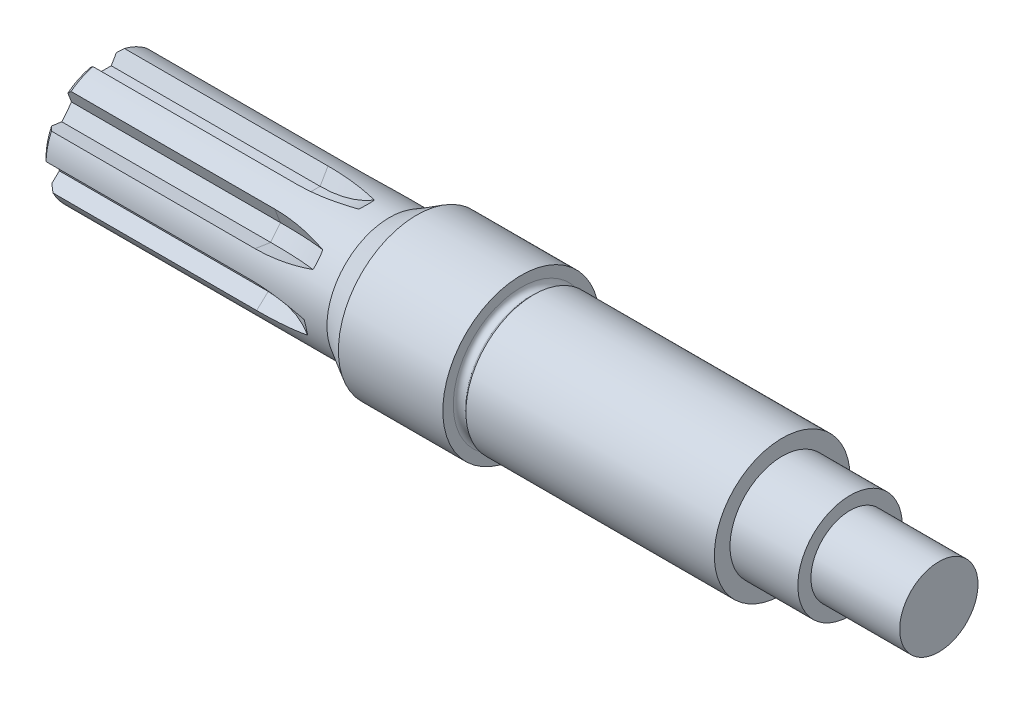
from build123d import *

# Parameters (mm, degrees)
KRUHOV_POLE1_COUNT = 7


with BuildPart() as part:
    # Skica1 → Rotovat1 (revolve)
    with BuildSketch(Plane.XY, mode=Mode.PRIVATE) as rotovat1_sk:
        with BuildLine():
            Line((-80, 2.5), (-61.443375673, 2.5))
            Line((-61.443375673, 2.5), (-60, 0))
            Line((-60, 0), (80, 0))
            Line((80, 0), (80, 7.5))
            Line((80, 7.5), (63, 7.5))
            Line((63, 7.5), (63, 10))
            Line((63, 10), (50, 10))
            Line((50, 10), (50, 13))
            Line((50, 13), (2.414213562, 13))
            Line((2.414213562, 13), (1.707106781, 12.292893219))
            ThreePointArc((1.707106781, 12.292893219), (0.617316568, 12.076120467), (0, 13))
            Line((0, 13), (0, 15))
            Line((0, 15), (-20, 15))
            Line((-20, 15), (-25.196152423, 12))
            Line((-25.196152423, 12), (-79, 12))
            Line((-79, 12), (-80, 11))
            Line((-80, 11), (-80, 2.5))
        make_face()
    revolve(rotovat1_sk.sketch.rotate(Axis((89.49015633, 0, 0), (-1, 0, 0)), 90), axis=Axis((89.49015633, 0, 0), (-1, 0, 0)))  # turned: the seam where the file's is

    # Odebrat tažením po křivce1: sweep along a path in Skica2
    with BuildLine(Plane.XY) as odebrat_ta_en_m_po_k_ivce1_path:
        Line((-80, 9), (-40, 9))
        ThreePointArc((-40, 9), (-30.024182748, 11.665552499), (-22.707471957, 18.951692985))
    # Skica3 → Odebrat tažením po křivce1 (sweep, cut)
    with BuildSketch(Plane.ZY.offset(80)):
        Polygon((-4.16819533, 13.621449875), (-1.5, 9), (1.5, 9), (4.16819533, 13.621449875), align=None)
    odebrat_ta_en_m_po_k_ivce1 = sweep(path=odebrat_ta_en_m_po_k_ivce1_path.line, mode=Mode.SUBTRACT)

    # Kruhové pole1: Odebrat tažením po křivce1 ×7 about axis
    kruhov_pole1_axis = Axis((0, 0, 0), (1, 0, 0))
    for i in range(1, KRUHOV_POLE1_COUNT):
        add(odebrat_ta_en_m_po_k_ivce1.rotate(kruhov_pole1_axis, i * 360 / KRUHOV_POLE1_COUNT), mode=Mode.SUBTRACT)


solid = part.part
